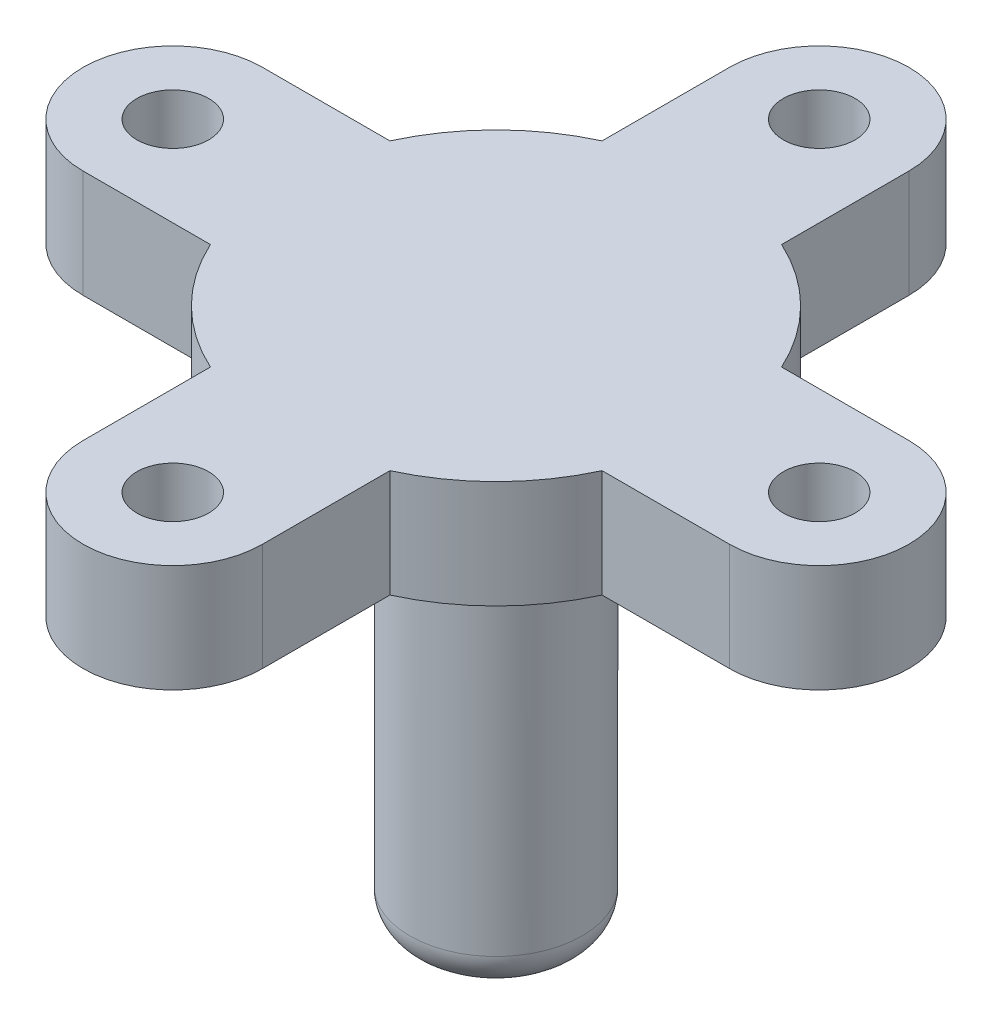
from build123d import *

# Parameters (mm, degrees)
SKETCH1_R           = 5
BOSS_EXTRUDE1_DEPTH = 7.5
SKETCH2_R           = 12
BOSS_EXTRUDE2_DEPTH = 60
FILLET1_R           = 5
SCALE1_SCALE        = 0.6


with BuildPart() as part:
    # Sketch1 → Boss-Extrude1 (new body, symmetric)
    with BuildSketch(Plane(origin=(0, 0, 0), x_dir=(1, 0, 0), z_dir=(0, 1, 0))):
        with BuildLine():
            Line((12.5, 45.011324124), (12.5, 27.271780287))
            ThreePointArc((12.5, 27.271780287), (21.213203436, 21.213203436), (27.271780287, 12.5))
            Line((27.271780287, 12.5), (45, 12.5))
            ThreePointArc((45, 12.5), (57.511322842, 0.00566206), (45.011324124, -12.5))
            Line((45.011324124, -12.5), (27.271780287, -12.5))
            ThreePointArc((27.271780287, -12.5), (21.213203436, -21.213203436), (12.5, -27.271780287))
            Line((12.5, -27.271780287), (12.5, -45))
            ThreePointArc((12.5, -45), (0.00566206, -57.511322842), (-12.5, -45.011324124))
            Line((-12.5, -45.011324124), (-12.5, -27.271780287))
            ThreePointArc((-12.5, -27.271780287), (-21.213203436, -21.213203436), (-27.271780287, -12.5))
            Line((-27.271780287, -12.5), (-45, -12.5))
            ThreePointArc((-45, -12.5), (-57.511322842, -0.00566206), (-45.011324124, 12.5))
            Line((-45.011324124, 12.5), (-27.271780287, 12.5))
            ThreePointArc((-27.271780287, 12.5), (-21.213203436, 21.213203436), (-12.5, 27.271780287))
            Line((-12.5, 27.271780287), (-12.5, 45))
            ThreePointArc((-12.5, 45), (-0.00566206, 57.511322842), (12.5, 45.011324124))
        make_face()
        with Locations((0, 45.011324124)):
            Circle(SKETCH1_R, mode=Mode.SUBTRACT)
        with Locations((45.011324124, 0)):
            Circle(SKETCH1_R, mode=Mode.SUBTRACT)
        with Locations((0, -45.011324124)):
            Circle(SKETCH1_R, mode=Mode.SUBTRACT)
        with Locations((-45.011324124, 0)):
            Circle(SKETCH1_R, mode=Mode.SUBTRACT)
    extrude(amount=BOSS_EXTRUDE1_DEPTH, both=True)

    # Sketch2 → Boss-Extrude2 (add)
    with BuildSketch(Plane.XZ.offset(7.5)):
        Circle(SKETCH2_R)
    extrude(amount=BOSS_EXTRUDE2_DEPTH)

    # Fillet1
    fillet1_edges = [part.edges().sort_by_distance(p)[0] for p in [
        (-12, -7.5, 0),
        (-12, -67.5, 0),
    ]]
    fillet(fillet1_edges, radius=FILLET1_R)


with BuildPart() as part_1:
    # Scale1: scaled about (0, -9.636129327, 0)
    add(part.part.scale(SCALE1_SCALE).moved(Location((0, -3.854451731, 0))))


solid = part_1.part
